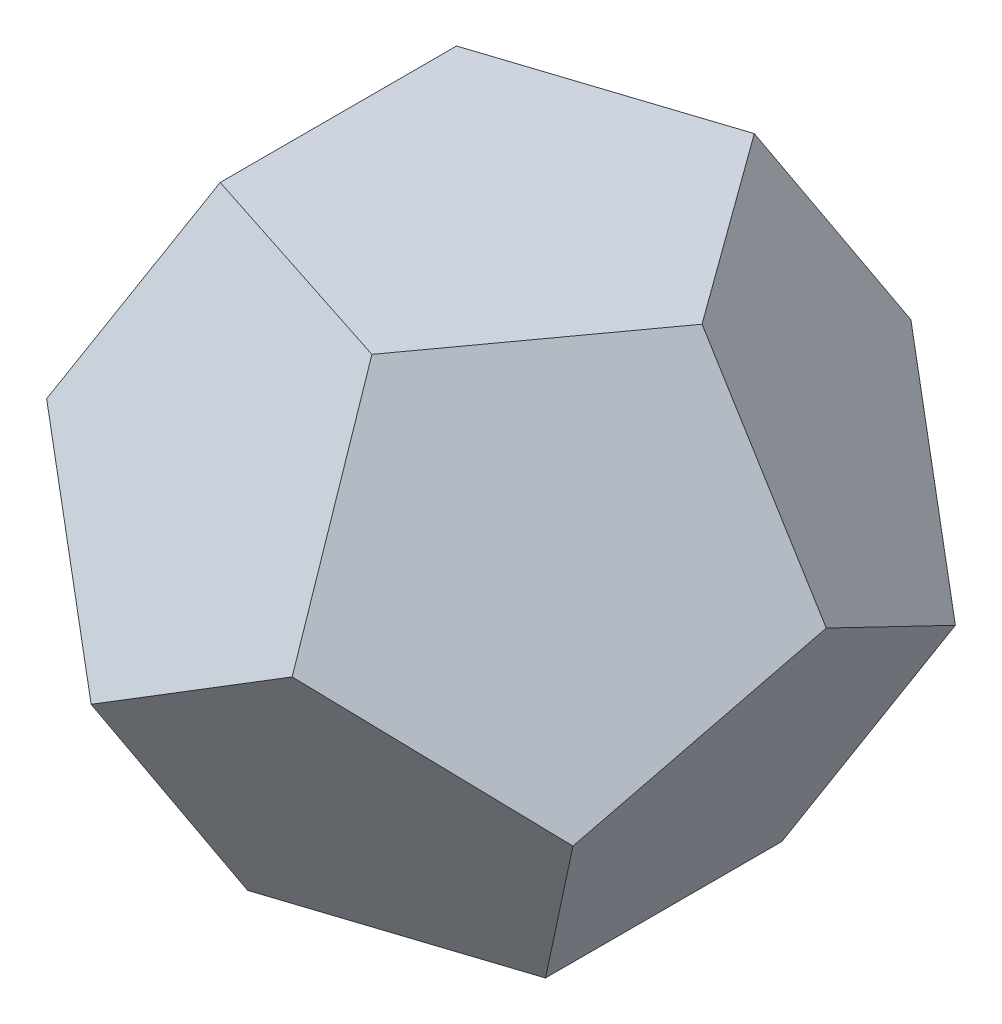
from build123d import *


with BuildPart() as body_1:
    # Skizze1 → Oberfläche-Ebene1: a flat surface bounded by the sketch
    with BuildSketch(Plane(origin=(0, 0, 0), x_dir=(1, 0, 0), z_dir=(0, 1, 0)), mode=Mode.PRIVATE) as oberfl_che_ebene1_1_region:
        Polygon((42.532540418, 0), (13.143277803, 40.450849719), (-34.409548012, 25), (-34.409548012, -25), (13.143277803, -40.450849719), align=None)
    oberfl_che_ebene1_1 = oberfl_che_ebene1_1_region.sketch.faces()[0]
    # Skizze2 → Oberfläche-Ebene2: a flat surface bounded by the sketch
    with BuildSketch(Plane(origin=(22.270327288, 13.763819205, -16.180339887), x_dir=(0.447213595, 0.276393202, 0.850650808), z_dir=(-0.723606798, -0.447213595, 0.525731112)), mode=Mode.PRIVATE) as oberfl_che_ebene2_2_region:
        Polygon((19.021130326, -22.360679775), (-28.531695489, -6.909830056), (-57.920958103, -47.360679775), (-28.531695489, -87.811529494), (19.021130326, -72.360679775), align=None)
    oberfl_che_ebene2_2 = oberfl_che_ebene2_2_region.sketch.faces()[0]
    # Skizze3 → Oberfläche-Ebene3: a flat surface bounded by the sketch
    with BuildSketch(Plane(origin=(22.270327288, 13.763819205, 16.180339887), x_dir=(-0.447213595, -0.276393202, 0.850650808), z_dir=(-0.723606798, -0.447213595, -0.525731112)), mode=Mode.PRIVATE) as oberfl_che_ebene3_3_region:
        Polygon((-19.021130326, -22.360679775), (-19.021130326, -72.360679775), (28.531695489, -87.811529494), (57.920958103, -47.360679775), (28.531695489, -6.909830056), align=None)
    oberfl_che_ebene3_3 = oberfl_che_ebene3_3_region.sketch.faces()[0]
    # Skizze4 → Oberfläche-Ebene4: a flat surface bounded by the sketch
    with BuildSketch(Plane(origin=(-8.506508084, 13.763819205, 26.180339887), x_dir=(-0.961044639, -0.128617124, -0.244644308), z_dir=(0.276393202, -0.447213595, -0.850650808)), mode=Mode.PRIVATE) as oberfl_che_ebene4_4_region:
        Polygon((13.27697134, -91.370916552), (-30.979599792, -68.103860192), (-22.527346819, -18.823444004), (26.953003932, -11.63352818), (49.081289498, -56.470332012), align=None)
    oberfl_che_ebene4_4 = oberfl_che_ebene4_4_region.sketch.faces()[0]
    # Skizze5 → Oberfläche-Ebene5: a flat surface bounded by the sketch
    with BuildSketch(Plane(origin=(-27.527638409, 13.763819205, 0), x_dir=(0, 0, -1), z_dir=(0.894427191, -0.447213595, 0)), mode=Mode.PRIVATE) as oberfl_che_ebene5_5_region:
        Polygon((40.450849719, -62.941243501), (0, -92.330506115), (-40.450849719, -62.941243501), (-25, -15.388417686), (25, -15.388417686), align=None)
    oberfl_che_ebene5_5 = oberfl_che_ebene5_5_region.sketch.faces()[0]
    # Skizze6 → Oberfläche-Ebene6: a flat surface bounded by the sketch
    with BuildSketch(Plane(origin=(-8.506508084, 13.763819205, -26.180339887), x_dir=(0.961044639, 0.128617124, -0.244644308), z_dir=(0.276393202, -0.447213595, 0.850650808)), mode=Mode.PRIVATE) as oberfl_che_ebene6_6_region:
        Polygon((-26.953003932, -11.63352818), (-49.081289498, -56.470332012), (-13.27697134, -91.370916552), (30.979599792, -68.103860192), (22.527346819, -18.823444004), align=None)
    oberfl_che_ebene6_6 = oberfl_che_ebene6_6_region.sketch.faces()[0]
    # Skizze7 → Oberfläche-Ebene7: a flat surface bounded by the sketch
    with BuildSketch(Plane(origin=(22.270327288, -36.034146493, 68.541019662), x_dir=(-0.961044639, -0.128617124, 0.244644308), z_dir=(-0.276393202, 0.447213595, -0.850650808)), mode=Mode.PRIVATE) as oberfl_che_ebene7_7_region:
        Polygon((45.301327056, -30.456972184), (36.849074082, -79.737388372), (-12.631276669, -86.927304196), (-34.759562235, -42.090500364), (1.044755924, -7.189915824), align=None)
    oberfl_che_ebene7_7 = oberfl_che_ebene7_7_region.sketch.faces()[0]
    # Skizze8 → Oberfläche-Ebene8: a flat surface bounded by the sketch
    with BuildSketch(Plane(origin=(-58.304473781, -36.034146493, 42.360679775), x_dir=(-0.447213595, -0.276393202, -0.850650808), z_dir=(0.723606798, 0.447213595, -0.525731112)), mode=Mode.PRIVATE) as oberfl_che_ebene8_8_region:
        Polygon((49.797965698, -72.360679775), (2.245139883, -87.811529494), (-27.144122732, -47.360679775), (2.245139883, -6.909830056), (49.797965698, -22.360679775), align=None)
    oberfl_che_ebene8_8 = oberfl_che_ebene8_8_region.sketch.faces()[0]
    # Skizze9 → Oberfläche-Ebene9: a flat surface bounded by the sketch
    with BuildSketch(Plane(origin=(-58.304473781, -36.034146493, -42.360679775), x_dir=(0.447213595, 0.276393202, -0.850650808), z_dir=(0.723606798, 0.447213595, 0.525731112)), mode=Mode.PRIVATE) as oberfl_che_ebene9_9_region:
        Polygon((27.144122732, -47.360679775), (-2.245139883, -87.811529494), (-49.797965698, -72.360679775), (-49.797965698, -22.360679775), (-2.245139883, -6.909830056), align=None)
    oberfl_che_ebene9_9 = oberfl_che_ebene9_9_region.sketch.faces()[0]
    # Skizze10 → Oberfläche-Ebene10: a flat surface bounded by the sketch
    with BuildSketch(Plane(origin=(22.270327288, -36.034146493, -68.541019662), x_dir=(-0.961044639, -0.128617124, -0.244644308), z_dir=(0.276393202, -0.447213595, -0.850650808)), mode=Mode.PRIVATE) as oberfl_che_ebene10_10_region:
        Polygon((-12.631276669, -86.927304196), (-34.759562235, -42.090500364), (1.044755924, -7.189915824), (45.301327056, -30.456972184), (36.849074082, -79.737388372), align=None)
    oberfl_che_ebene10_10 = oberfl_che_ebene10_10_region.sketch.faces()[0]
    # Skizze11 → Oberfläche-Ebene11: a flat surface bounded by the sketch
    with BuildSketch(Plane(origin=(72.068292986, -36.034146493, 0), x_dir=(0, 0, -1), z_dir=(0.894427191, -0.447213595, 0)), mode=Mode.PRIVATE) as oberfl_che_ebene11_11_region:
        Polygon((-40.450849719, -36.654687895), (-25, -84.207513709), (25, -84.207513709), (40.450849719, -36.654687895), (0, -7.26542528), align=None)
    oberfl_che_ebene11_11 = oberfl_che_ebene11_11_region.sketch.faces()[0]
    # Skizze12 → Oberfläche-Ebene12: a flat surface bounded by the sketch
    with BuildSketch(Plane(origin=(0, -111.351636441, 0), x_dir=(1, 0, 0), z_dir=(0, 1, 0)), mode=Mode.PRIVATE) as oberfl_che_ebene12_12_region:
        Polygon((-13.143277803, -40.450849719), (34.409548012, -25), (34.409548012, 25), (-13.143277803, 40.450849719), (-42.532540418, 0), align=None)
    oberfl_che_ebene12_12 = oberfl_che_ebene12_12_region.sketch.faces()[0]
    # Oberfläche-Zusammenfügen1: the surfaces knitted into a closed skin and filled: a solid
    add(Solid(Shell(Face.sew_faces(oberfl_che_ebene1_1.faces() + oberfl_che_ebene2_2.faces() + oberfl_che_ebene3_3.faces() + oberfl_che_ebene4_4.faces() + oberfl_che_ebene5_5.faces() + oberfl_che_ebene6_6.faces() + oberfl_che_ebene7_7.faces() + oberfl_che_ebene8_8.faces() + oberfl_che_ebene9_9.faces() + oberfl_che_ebene10_10.faces() + oberfl_che_ebene11_11.faces() + oberfl_che_ebene12_12.faces())[0])))


with BuildPart() as body_2:
    # Skizze-y1 → Oberfläche-Ebene-y1: a flat surface bounded by the sketch
    with BuildSketch(Plane(origin=(0, 0, 0), x_dir=(0.982246946, -0.1517655, -0.11026409), z_dir=(0.187592474, 0.794654472, 0.577350269)), mode=Mode.PRIVATE) as oberfl_che_ebene_y1_13_region:
        Polygon((41.015551826, -41.770509831), (-15.66654673, -56.405764747), (0, 0), align=None)
    oberfl_che_ebene_y1_13 = oberfl_che_ebene_y1_13_region.sketch.faces()[0]
    # Skizze-y2 → Oberfläche-Ebene-y2: a flat surface bounded by the sketch
    with BuildSketch(Plane(origin=(0, 0, 0), x_dir=(0.871089969, 0.448028881, 0.201177502), z_dir=(-0.491123473, 0.794654472, 0.35682209)), mode=Mode.PRIVATE) as oberfl_che_ebene_y2_14_region:
        Polygon((-17.665704156, -55.811951048), (0, 0), (-57.167419521, -12.607026949), align=None)
    oberfl_che_ebene_y2_14 = oberfl_che_ebene_y2_14_region.sketch.faces()[0]
    # Skizze-y3 → Oberfläche-Ebene-y3: a flat surface bounded by the sketch
    with BuildSketch(Plane(origin=(0, 0, 0), x_dir=(0.871089969, 0.448028881, -0.201177502), z_dir=(-0.491123473, 0.794654472, -0.35682209)), mode=Mode.PRIVATE) as oberfl_che_ebene_y3_15_region:
        Polygon((-57.167419521, 12.607026949), (0, 0), (-17.665704156, 55.811951048), align=None)
    oberfl_che_ebene_y3_15 = oberfl_che_ebene_y3_15_region.sketch.faces()[0]
    # Skizze-y4 → Oberfläche-Ebene-y4: a flat surface bounded by the sketch
    with BuildSketch(Plane(origin=(0, 0, 0), x_dir=(0.982246946, -0.1517655, 0.11026409), z_dir=(0.187592474, 0.794654472, -0.577350269)), mode=Mode.PRIVATE) as oberfl_che_ebene_y4_16_region:
        Polygon((41.015551826, 41.770509831), (0, 0), (-15.66654673, 56.405764747), align=None)
    oberfl_che_ebene_y4_16 = oberfl_che_ebene_y4_16_region.sketch.faces()[0]
    # Skizze-y5 → Oberfläche-Ebene-y5: a flat surface bounded by the sketch
    with BuildSketch(Plane(origin=(0, 0, 0), x_dir=(0.794654472, -0.607061998, 0), z_dir=(0.607061998, 0.794654472, 0)), mode=Mode.PRIVATE) as oberfl_che_ebene_y5_17_region:
        Polygon((0, 0), (50.698010191, -29.270509831), (50.698010191, 29.270509831), align=None)
    oberfl_che_ebene_y5_17 = oberfl_che_ebene_y5_17_region.sketch.faces()[0]
    # Skizze-y6 → Oberfläche-Ebene-y6: a flat surface bounded by the sketch
    with BuildSketch(Plane(origin=(10.258945124, 6.340376775, 31.573786517), x_dir=(-0.952821564, 0.05975949, 0.297590105), z_dir=(-0.303530999, -0.187592474, -0.934172359)), mode=Mode.PRIVATE) as oberfl_che_ebene_y6_18_region:
        Polygon((-5.383455577, -88.322160488), (-31.515297879, -35.937259982), (26.917277885, -39.498870954), align=None)
    oberfl_che_ebene_y6_18 = oberfl_che_ebene_y6_18_region.sketch.faces()[0]
    # Skizze-y7 → Oberfläche-Ebene-y7: a flat surface bounded by the sketch
    with BuildSketch(Plane(origin=(-16.599321899, -10.258945124, 51.087459737), x_dir=(-0.952821564, 0.05975949, -0.297590105), z_dir=(0.303530999, 0.187592474, -0.934172359)), mode=Mode.PRIVATE) as oberfl_che_ebene_y7_19_region:
        Polygon((-33.571594932, -69.673323329), (-1.27086147, -20.850033795), (24.860980832, -73.234934301), align=None)
    oberfl_che_ebene_y7_19 = oberfl_che_ebene_y7_19_region.sketch.faces()[0]
    # Skizze-y8 → Oberfläche-Ebene-y8: a flat surface bounded by the sketch
    with BuildSketch(Plane(origin=(-26.858267023, 6.340376775, 19.513673221), x_dir=(0.561905566, -0.132647911, 0.816496581), z_dir=(-0.794654472, 0.187592474, 0.577350269)), mode=Mode.PRIVATE) as oberfl_che_ebene_y8_20_region:
        Polygon((11.9496356, -87.675491651), (34.105478461, -33.489057831), (-23.899271199, -41.394751981), align=None)
    oberfl_che_ebene_y8_20 = oberfl_che_ebene_y8_20_region.sketch.faces()[0]
    # Skizze-y9 → Oberfläche-Ebene-y9: a flat surface bounded by the sketch
    with BuildSketch(Plane(origin=(-53.716534046, -10.258945124, 0), x_dir=(0, 0, 1), z_dir=(-0.982246946, -0.187592474, 0)), mode=Mode.PRIVATE) as oberfl_che_ebene_y9_21_region:
        Polygon((-29.270509831, -71.586739165), (29.270509831, -71.586739165), (0, -20.888728973), align=None)
    oberfl_che_ebene_y9_21 = oberfl_che_ebene_y9_21_region.sketch.faces()[0]
    # Skizze-y10 → Oberfläche-Ebene-y10: a flat surface bounded by the sketch
    with BuildSketch(Plane(origin=(-26.858267023, 6.340376775, -19.513673221), x_dir=(0.561905566, -0.132647911, -0.816496581), z_dir=(0.794654472, -0.187592474, 0.577350269)), mode=Mode.PRIVATE) as oberfl_che_ebene_y10_22_region:
        Polygon((-23.899271199, -41.394751981), (11.9496356, -87.675491651), (34.105478461, -33.489057831), align=None)
    oberfl_che_ebene_y10_22 = oberfl_che_ebene_y10_22_region.sketch.faces()[0]
    # Skizze-y11 → Oberfläche-Ebene-y11: a flat surface bounded by the sketch
    with BuildSketch(Plane(origin=(-16.599321899, -10.258945124, -51.087459737), x_dir=(-0.952821564, 0.05975949, 0.297590105), z_dir=(-0.303530999, -0.187592474, -0.934172359)), mode=Mode.PRIVATE) as oberfl_che_ebene_y11_23_region:
        Polygon((-33.571594932, -69.673323329), (24.860980832, -73.234934301), (-1.27086147, -20.850033795), align=None)
    oberfl_che_ebene_y11_23 = oberfl_che_ebene_y11_23_region.sketch.faces()[0]
    # Skizze-y12 → Oberfläche-Ebene-y12: a flat surface bounded by the sketch
    with BuildSketch(Plane(origin=(10.258945124, 6.340376775, -31.573786517), x_dir=(0.952821564, -0.05975949, 0.297590105), z_dir=(-0.303530999, -0.187592474, 0.934172359)), mode=Mode.PRIVATE) as oberfl_che_ebene_y12_24_region:
        Polygon((-26.917277885, -39.498870954), (5.383455577, -88.322160488), (31.515297879, -35.937259982), align=None)
    oberfl_che_ebene_y12_24 = oberfl_che_ebene_y12_24_region.sketch.faces()[0]
    # Skizze-y13 → Oberfläche-Ebene-y13: a flat surface bounded by the sketch
    with BuildSketch(Plane(origin=(43.457588922, -10.258945124, -31.573786517), x_dir=(-0.561905566, 0.132647911, -0.816496581), z_dir=(0.794654472, -0.187592474, -0.577350269)), mode=Mode.PRIVATE) as oberfl_che_ebene_y13_25_region:
        Polygon((19.334916553, -74.883809811), (-38.669833107, -66.978115661), (-2.820926308, -20.69737599), align=None)
    oberfl_che_ebene_y13_25 = oberfl_che_ebene_y13_25_region.sketch.faces()[0]
    # Skizze-y14 → Oberfläche-Ebene-y14: a flat surface bounded by the sketch
    with BuildSketch(Plane(origin=(33.198643798, 6.340376775, 0), x_dir=(0, 0, 1), z_dir=(-0.982246946, -0.187592474, 0)), mode=Mode.PRIVATE) as oberfl_che_ebene_y14_26_region:
        Polygon((0, -88.486075895), (-29.270509831, -37.788065704), (29.270509831, -37.788065704), align=None)
    oberfl_che_ebene_y14_26 = oberfl_che_ebene_y14_26_region.sketch.faces()[0]
    # Skizze-y15 → Oberfläche-Ebene-y15: a flat surface bounded by the sketch
    with BuildSketch(Plane(origin=(43.457588922, -10.258945124, 31.573786517), x_dir=(-0.561905566, 0.132647911, 0.816496581), z_dir=(-0.794654472, 0.187592474, -0.577350269)), mode=Mode.PRIVATE) as oberfl_che_ebene_y15_27_region:
        Polygon((-38.669833107, -66.978115661), (-2.820926308, -20.69737599), (19.334916553, -74.883809811), align=None)
    oberfl_che_ebene_y15_27 = oberfl_che_ebene_y15_27_region.sketch.faces()[0]
    # Skizze-y16 → Oberfläche-Ebene-y16: a flat surface bounded by the sketch
    with BuildSketch(Plane(origin=(-16.599321899, -70.315855945, 51.087459737), x_dir=(0.982246946, -0.1517655, 0.11026409), z_dir=(0.187592474, 0.794654472, -0.577350269)), mode=Mode.PRIVATE) as oberfl_che_ebene_y16_28_region:
        Polygon((32.56588346, 9.045084972), (16.89933673, 65.450849719), (-24.116215095, 23.680339887), align=None)
    oberfl_che_ebene_y16_28 = oberfl_che_ebene_y16_28_region.sketch.faces()[0]
    # Skizze-y17 → Oberfläche-Ebene-y17: a flat surface bounded by the sketch
    with BuildSketch(Plane(origin=(-53.716534046, -70.315855945, 0), x_dir=(0.794654472, -0.607061998, 0), z_dir=(0.607061998, 0.794654472, 0)), mode=Mode.PRIVATE) as oberfl_che_ebene_y17_29_region:
        Polygon((16.89933673, -29.270509831), (67.597346922, 0), (16.89933673, 29.270509831), align=None)
    oberfl_che_ebene_y17_29 = oberfl_che_ebene_y17_29_region.sketch.faces()[0]
    # Skizze-y18 → Oberfläche-Ebene-y18: a flat surface bounded by the sketch
    with BuildSketch(Plane(origin=(-16.599321899, -70.315855945, -51.087459737), x_dir=(-0.982246946, 0.1517655, 0.11026409), z_dir=(-0.187592474, -0.794654472, -0.577350269)), mode=Mode.PRIVATE) as oberfl_che_ebene_y18_30_region:
        Polygon((24.116215095, -23.680339887), (-16.89933673, -65.450849719), (-32.56588346, -9.045084972), align=None)
    oberfl_che_ebene_y18_30 = oberfl_che_ebene_y18_30_region.sketch.faces()[0]
    # Skizze-y19 → Oberfläche-Ebene-y19: a flat surface bounded by the sketch
    with BuildSketch(Plane(origin=(43.457588922, -70.315855945, -31.573786517), x_dir=(-0.871089969, -0.448028881, -0.201177502), z_dir=(0.491123473, -0.794654472, -0.35682209)), mode=Mode.PRIVATE) as oberfl_che_ebene_y19_31_region:
        Polygon((49.888749118, -45.612651998), (32.223044962, 10.19929905), (-7.278670403, -33.005625049), align=None)
    oberfl_che_ebene_y19_31 = oberfl_che_ebene_y19_31_region.sketch.faces()[0]
    # Skizze-y20 → Oberfläche-Ebene-y20: a flat surface bounded by the sketch
    with BuildSketch(Plane(origin=(43.457588922, -70.315855945, 31.573786517), x_dir=(0.871089969, 0.448028881, -0.201177502), z_dir=(-0.491123473, 0.794654472, -0.35682209)), mode=Mode.PRIVATE) as oberfl_che_ebene_y20_32_region:
        Polygon((-32.223044962, -10.19929905), (7.278670403, 33.005625049), (-49.888749118, 45.612651998), align=None)
    oberfl_che_ebene_y20_32 = oberfl_che_ebene_y20_32_region.sketch.faces()[0]
    # Oberfläche-Zusammenfügen2: the surfaces knitted into a closed skin and filled: a solid
    add(Solid(Shell(Face.sew_faces(oberfl_che_ebene_y1_13.faces() + oberfl_che_ebene_y2_14.faces() + oberfl_che_ebene_y3_15.faces() + oberfl_che_ebene_y4_16.faces() + oberfl_che_ebene_y5_17.faces() + oberfl_che_ebene_y6_18.faces() + oberfl_che_ebene_y7_19.faces() + oberfl_che_ebene_y8_20.faces() + oberfl_che_ebene_y9_21.faces() + oberfl_che_ebene_y10_22.faces() + oberfl_che_ebene_y11_23.faces() + oberfl_che_ebene_y12_24.faces() + oberfl_che_ebene_y13_25.faces() + oberfl_che_ebene_y14_26.faces() + oberfl_che_ebene_y15_27.faces() + oberfl_che_ebene_y16_28.faces() + oberfl_che_ebene_y17_29.faces() + oberfl_che_ebene_y18_30.faces() + oberfl_che_ebene_y19_31.faces() + oberfl_che_ebene_y20_32.faces())[0])))


solid = Compound([body_1.part, body_2.part])
